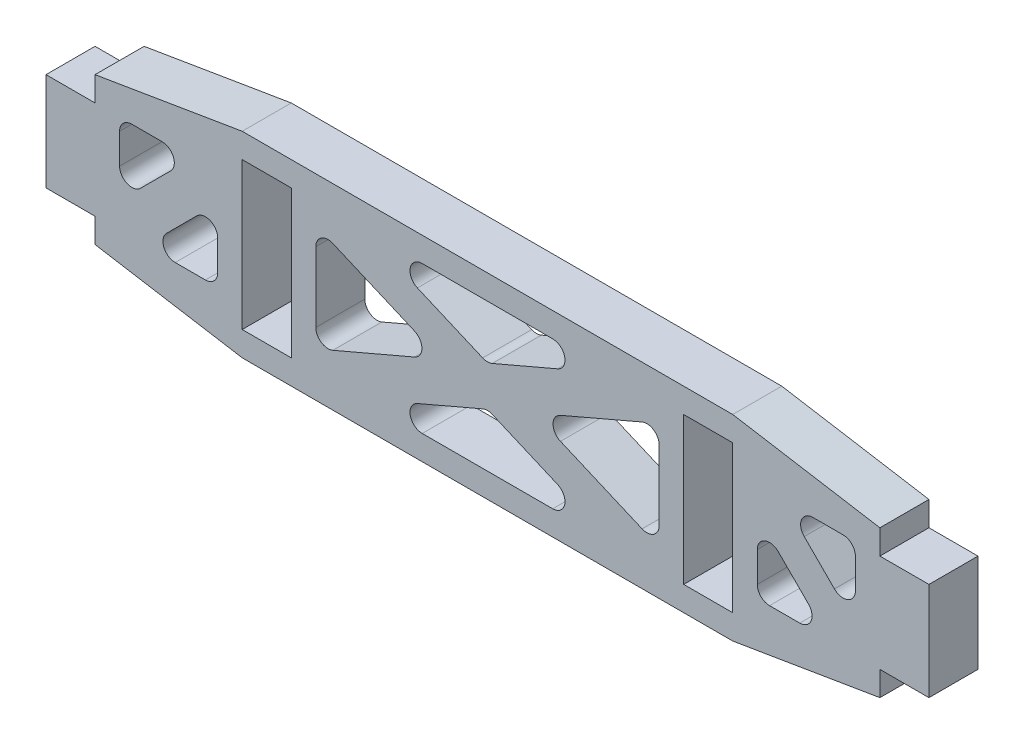
from build123d import *

# Parameters (mm, degrees)
SKETCH1_W           = 6.35
SKETCH1_H           = 19.05
BOSS_EXTRUDE1_DEPTH = 3.175
CUT_EXTRUDE1_DEPTH  = 7.35
FILLET1_R           = 1.5875


with BuildPart() as part:
    # Sketch1 → Boss-Extrude1 (new body, symmetric)
    with BuildSketch(Plane.XY):
        Polygon((-50.8, -9.525), (-50.8, -6.35), (-57.15, -6.35), (-57.15, 6.35), (-50.8, 6.35), (-50.8, 9.525), (-31.75, 12.7), (31.75, 12.7), (50.8, 9.525), (50.8, 6.35), (57.15, 6.35), (57.15, -6.35), (50.8, -6.35), (50.8, -9.525), (31.75, -12.7), (-31.75, -12.7), align=None)
        with Locations((-28.575, 0)):
            Rectangle(SKETCH1_W, SKETCH1_H, mode=Mode.SUBTRACT)
        with Locations((28.575, 0)):
            Rectangle(SKETCH1_W, SKETCH1_H, mode=Mode.SUBTRACT)
    extrude(amount=BOSS_EXTRUDE1_DEPTH, both=True)

    # Sketch2 → Cut-Extrude1 (cut, through all)
    with BuildSketch(Plane.XY.offset(3.175)):
        Polygon((-38.292596045, 6.35), (-47.625, 6.35), (-47.625, -2.982403955), align=None)
        Polygon((-34.925, 2.982403955), (-44.257403955, -6.35), (-34.925, -6.35), align=None)
        Polygon((-22.225, -6.934277185), (-6.045019903, 0), (-22.225, 6.934277185), align=None)
        Polygon((-16.179980097, 9.525), (0, 2.590722815), (16.179980097, 9.525), align=None)
        Polygon((6.045019903, 0), (22.225, -6.934277185), (22.225, 6.934277185), align=None)
        Polygon((-16.179980097, -9.525), (16.179980097, -9.525), (0, -2.590722815), align=None)
        Polygon((44.257403955, -6.35), (34.925, 2.982403955), (34.925, -6.35), align=None)
        Polygon((47.625, 6.35), (38.292596045, 6.35), (47.625, -2.982403955), align=None)
    extrude(amount=-CUT_EXTRUDE1_DEPTH, mode=Mode.SUBTRACT)

    # Fillet1
    fillet1_edges = [part.edges().sort_by_distance(p)[0] for p in [
        (16.179980097, 9.525, 0),
        (0, 2.590722815, 0),
        (-16.179980097, 9.525, 0),
        (22.225, 6.934277185, 0),
        (22.225, -6.934277185, 0),
        (6.045019903, 0, 0),
        (-6.045019903, 0, 0),
        (-22.225, -6.934277185, 0),
        (-22.225, 6.934277185, 0),
        (-34.925, 2.982403955, 0),
        (-34.925, -6.35, 0),
        (-44.257403955, -6.35, 0),
        (38.292596045, 6.35, 0),
        (47.625, 6.35, 0),
        (47.625, -2.982403955, 0),
        (44.257403955, -6.35, 0),
        (34.925, -6.35, 0),
        (34.925, 2.982403955, 0),
        (0, -2.590722815, 0),
        (16.179980097, -9.525, 0),
        (-16.179980097, -9.525, 0),
        (-38.292596045, 6.35, 0),
        (-47.625, -2.982403955, 0),
        (-47.625, 6.35, 0),
    ]]
    fillet(fillet1_edges, radius=FILLET1_R)


solid = part.part
